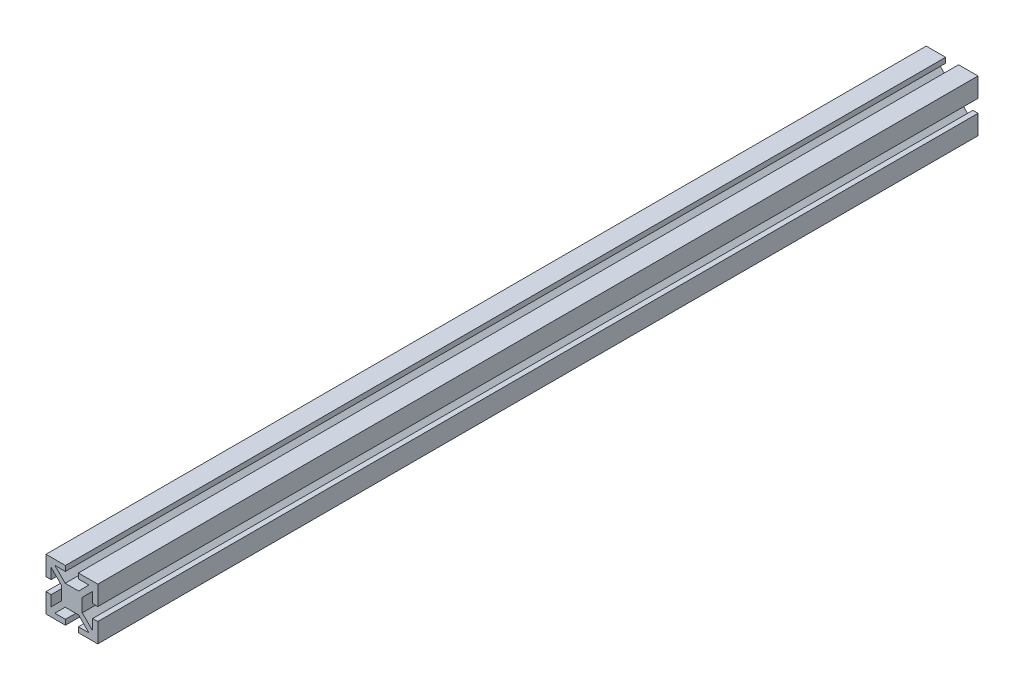
from build123d import *

# Parameters (mm, degrees)
BOSS_EXTRUDE1_DEPTH = 170


with BuildPart() as part:
    # Sketch1 → Boss-Extrude1 (new body, symmetric)
    with BuildSketch(Plane.XY):
        Polygon((-2.585786438, 4), (2.585786438, 4), (6.585786438, 8), (2.5, 8), (2.5, 10), (10, 10), (10, 2.5), (8, 2.5), (8, 6.585786438), (4, 2.585786438), (4, -2.585786438), (8, -6.585786438), (8, -2.5), (10, -2.5), (10, -10), (2.5, -10), (2.5, -8), (6.585786438, -8), (2.585786438, -4), (-2.585786438, -4), (-6.585786438, -8), (-2.5, -8), (-2.5, -10), (-10, -10), (-10, -2.5), (-8, -2.5), (-8, -6.585786438), (-4, -2.585786438), (-4, 2.585786438), (-8, 6.585786438), (-8, 2.5), (-10, 2.5), (-10, 10), (-2.5, 10), (-2.5, 8), (-6.585786438, 8), align=None)
    extrude(amount=BOSS_EXTRUDE1_DEPTH, both=True)


solid = part.part
